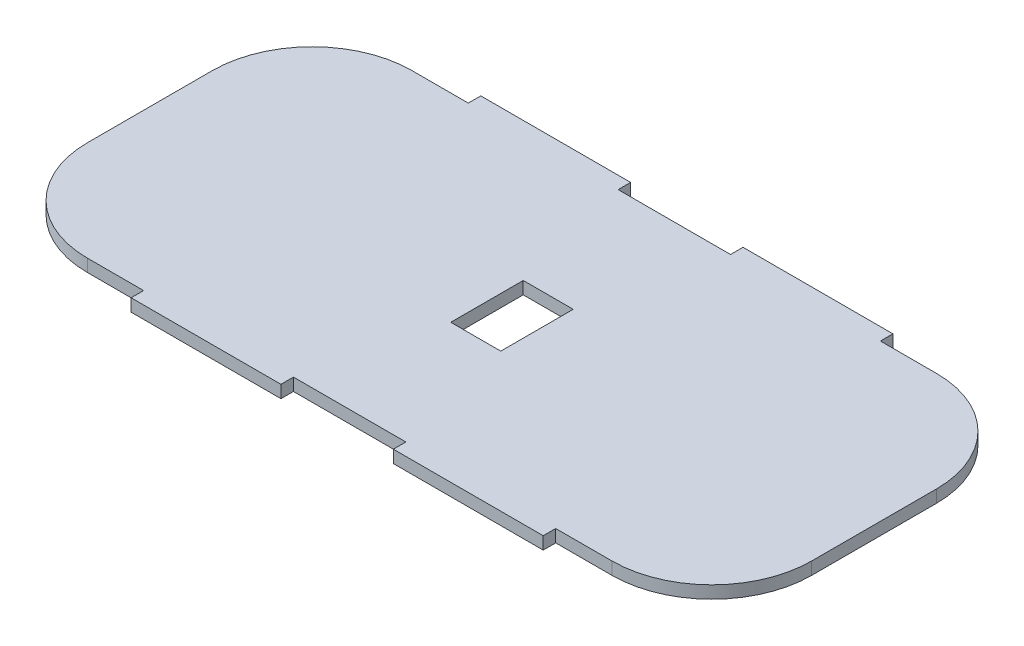
from build123d import *

# Parameters (mm, degrees)
BOSS_EXTRUDE2_DEPTH = 2.5
SKETCH3_W           = 10
SKETCH3_H           = 14.5
CUT_EXTRUDE3_DEPTH  = 40


with BuildPart() as part:
    # Sketch1 → Boss-Extrude2 (new body)
    with BuildSketch(Plane(origin=(0, 0, 0), x_dir=(1, 0, 0), z_dir=(0, 1, 0))):
        with BuildLine():
            Line((-52.5, 32.5), (-41.25, 32.5))
            Line((-41.25, 32.5), (-41.25, 35))
            Line((-41.25, 35), (-11.25, 35))
            Line((-11.25, 35), (-11.25, 32.5))
            Line((-11.25, 32.5), (11.25, 32.5))
            Line((11.25, 32.5), (11.25, 35))
            Line((11.25, 35), (41.25, 35))
            Line((41.25, 35), (41.25, 32.5))
            Line((41.25, 32.5), (52.5, 32.5))
            ThreePointArc((52.5, 32.5), (66.642135624, 26.642135624), (72.5, 12.5))
            Line((72.5, 12.5), (72.5, -12.5))
            ThreePointArc((72.5, -12.5), (66.642135624, -26.642135624), (52.5, -32.5))
            Line((52.5, -32.5), (41.25, -32.5))
            Line((41.25, -32.5), (41.25, -35))
            Line((41.25, -35), (11.25, -35))
            Line((11.25, -35), (11.25, -32.5))
            Line((11.25, -32.5), (-11.25, -32.5))
            Line((-11.25, -32.5), (-11.25, -35))
            Line((-11.25, -35), (-41.25, -35))
            Line((-41.25, -35), (-41.25, -32.5))
            Line((-41.25, -32.5), (-52.5, -32.5))
            ThreePointArc((-52.5, -32.5), (-66.642135624, -26.642135624), (-72.5, -12.5))
            Line((-72.5, -12.5), (-72.5, 12.5))
            ThreePointArc((-72.5, 12.5), (-66.642135624, 26.642135624), (-52.5, 32.5))
        make_face()
    extrude(amount=BOSS_EXTRUDE2_DEPTH)

    # Sketch3 → Cut-Extrude3 (cut)
    with BuildSketch(Plane.XZ):
        Rectangle(SKETCH3_W, SKETCH3_H)
    extrude(amount=-CUT_EXTRUDE3_DEPTH, mode=Mode.SUBTRACT)


solid = part.part
